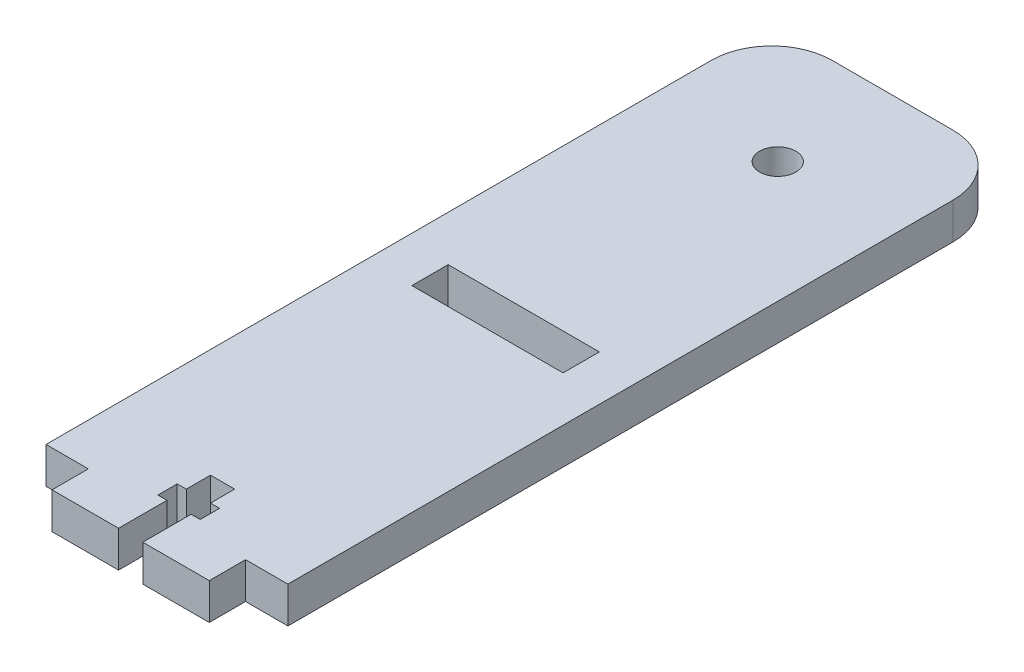
from build123d import *

# Parameters (mm, degrees)
SKETCH1_R           = 3
SKETCH1_W           = 25
SKETCH1_H           = 6
BOSS_EXTRUDE1_DEPTH = 6


with BuildPart() as part:
    # Sketch1 → Boss-Extrude1 (new body)
    with BuildSketch(Plane(origin=(0, 0, 0), x_dir=(1, 0, 0), z_dir=(0, 1, 0))):
        with BuildLine():
            Line((-10, 62.761766306), (10, 62.761766306))
            ThreePointArc((10, 62.761766306), (17.071067812, 59.832834118), (20, 52.761766306))
            Line((20, 52.761766306), (20, -57.238233694))
            Line((20, -57.238233694), (13, -57.238233694))
            Line((13, -57.238233694), (13, -63.238233694))
            Line((13, -63.238233694), (2, -63.238233694))
            Line((2, -63.238233694), (2, -55.238233694))
            Line((2, -55.238233694), (3.5, -55.238233694))
            Line((3.5, -55.238233694), (3.5, -52.038233694))
            Line((3.5, -52.038233694), (2, -52.038233694))
            Line((2, -52.038233694), (2, -48.038233694))
            Line((2, -48.038233694), (-2, -48.038233694))
            Line((-2, -48.038233694), (-2, -52.038233694))
            Line((-2, -52.038233694), (-3.5, -52.038233694))
            Line((-3.5, -52.038233694), (-3.5, -55.238233694))
            Line((-3.5, -55.238233694), (-2, -55.238233694))
            Line((-2, -55.238233694), (-2, -63.238233694))
            Line((-2, -63.238233694), (-13, -63.238233694))
            Line((-13, -63.238233694), (-13, -57.238233694))
            Line((-13, -57.238233694), (-20, -57.238233694))
            Line((-20, -57.238233694), (-20, 52.761766306))
            ThreePointArc((-20, 52.761766306), (-17.071067812, 59.832834118), (-10, 62.761766306))
        make_face()
        with Locations((0, 43.761766306)):
            Circle(SKETCH1_R, mode=Mode.SUBTRACT)
        with Locations((0, -1.238233694)):
            Rectangle(SKETCH1_W, SKETCH1_H, mode=Mode.SUBTRACT)
    extrude(amount=BOSS_EXTRUDE1_DEPTH)


solid = part.part
